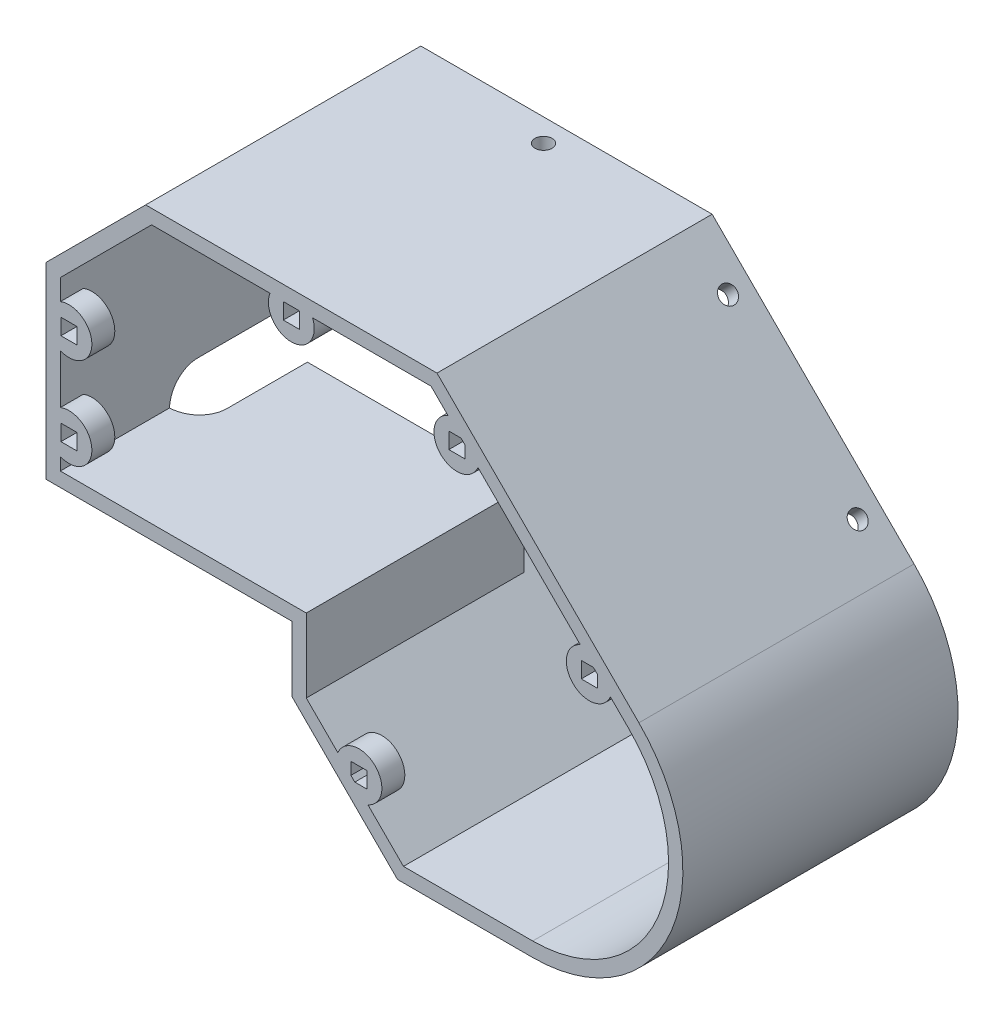
from build123d import *

# Parameters (mm, degrees)
RESSALTO_EXTRUS_O1_DEPTH = 48
ESBO_O12_R               = 1.5
CORTE_EXTRUS_O10_DEPTH   = 10
ESBO_O13_R               = 1.5
CORTE_EXTRUS_O11_DEPTH   = 10
ESBO_O14_R               = 1.5
CORTE_EXTRUS_O12_DEPTH   = 10
ESBO_O15_R               = 1.5
CORTE_EXTRUS_O13_DEPTH   = 10
CORTE_EXTRUS_O14_DEPTH   = 10
ESBO_O17_R               = 4
ESBO_O17_W               = 2.8
ESBO_O17_H               = 2.8
RESSALTO_EXTRUS_O2_DEPTH = 4
CORTE_EXTRUS_O15_DEPTH   = 10
ESBO_O20_R               = 86.409415436
CORTE_EXTRUS_O16_DEPTH   = 48


with BuildPart() as part:
    # Model → Ressalto-extrusão1 (new body)
    with BuildSketch(Plane.XY):
        with BuildLine():
            Line((-0.7, 0), (39, 0))
            Line((39, 0), (39.7, 0))
            Line((39.7, 0), (39.7, -11.380317396))
            Line((39.7, -11.380317396), (50.182424304, -21.8627417))
            Line((50.182424304, -21.8627417), (58.119682605, -29.8))
            Line((58.119682605, -29.8), (81.7, -29.8))
            ThreePointArc((81.7, -29.8), (105.905643752, -13.626305928), (100.226197667, 14.926197667))
            Line((100.226197667, 14.926197667), (65.00338056, 50.149014774))
            Line((65.00338056, 50.149014774), (50.111140335, 50.149014774))
            Line((50.111140335, 50.149014774), (14.181595121, 50.149014774))
            Line((14.181595121, 50.149014774), (-3.2, 32.767419653))
            Line((-3.2, 32.767419653), (-3.2, 5))
            Line((-3.2, 5), (-3.2, 0))
            Line((-3.2, 0), (-0.7, 0))
        make_face()
        with BuildLine():
            Line((-0.7, 2.5), (39, 2.5))
            Line((39, 2.5), (39.7, 2.5))
            Line((39.7, 2.5), (42.2, 2.5))
            Line((42.2, 2.5), (42.2, -10.34478349))
            Line((42.2, -10.34478349), (51.950191257, -20.094974747))
            Line((51.950191257, -20.094974747), (59.15521651, -27.3))
            Line((59.15521651, -27.3), (81.7, -27.3))
            ThreePointArc((81.7, -27.3), (103.595944921, -12.669597347), (98.458430714, 13.158430714))
            Line((98.458430714, 13.158430714), (63.967846654, 47.649014774))
            Line((63.967846654, 47.649014774), (50.111140335, 47.649014774))
            Line((50.111140335, 47.649014774), (15.217129027, 47.649014774))
            Line((15.217129027, 47.649014774), (-0.7, 31.731885747))
            Line((-0.7, 31.731885747), (-0.7, 2.5))
        make_face(mode=Mode.SUBTRACT)
    extrude(amount=RESSALTO_EXTRUS_O1_DEPTH)

    # Esboço12 → Corte-extrusão10 (cut)
    with BuildSketch(Plane(origin=(57.576197667, 57.576197667, 0), x_dir=(0, 0, -1), z_dir=(0.707106781, 0.707106781, 0))):
        with Locations((-44, -20.072657306)):
            Circle(ESBO_O12_R)
        with Locations((-44, -52.072657306)):
            Circle(ESBO_O12_R)
    extrude(amount=-CORTE_EXTRUS_O10_DEPTH, mode=Mode.SUBTRACT)

    # Esboço13 → Corte-extrusão11 (cut)
    with BuildSketch(Plane(origin=(0, 50.149014774, 0), x_dir=(1, 0, 0), z_dir=(0, 1, 0))):
        with Locations((39.59248784, -44)):
            Circle(ESBO_O13_R)
    extrude(amount=-CORTE_EXTRUS_O11_DEPTH, mode=Mode.SUBTRACT)

    # Esboço14 → Corte-extrusão12 (cut)
    with BuildSketch(Plane.ZY.offset(3.2)):
        with Locations((44, 23.701037279)):
            Circle(ESBO_O14_R)
        with Locations((44, 7.740898975)):
            Circle(ESBO_O14_R)
    extrude(amount=-CORTE_EXTRUS_O12_DEPTH, mode=Mode.SUBTRACT)

    # Esboço15 → Corte-extrusão13 (cut)
    with BuildSketch(Plane(origin=(14.159841302, 14.159841302, 0), x_dir=(0, 0, 1), z_dir=(-0.707106781, -0.707106781, 0))):
        with Locations((44, -46.881179593)):
            Circle(ESBO_O15_R)
    extrude(amount=-CORTE_EXTRUS_O13_DEPTH, mode=Mode.SUBTRACT)

    # Esboço16 → Corte-extrusão14 (cut)
    with BuildSketch(Plane.XY.offset(48)):
        Polygon((39.7, 0), (39.7, -7.84478349), (42.2, -10.34478349), (42.2, 2.5), (-0.7, 2.5), (-0.7, 0), align=None)
    extrude(amount=-CORTE_EXTRUS_O14_DEPTH, mode=Mode.SUBTRACT)

    # Esboço17 → Ressalto-extrusão2 (add)
    with BuildSketch(Plane(origin=(0, 0, 0), x_dir=(-1, 0, 0), z_dir=(0, 0, -1))):
        with Locations((-91.568699638, 17.926841447)):
            Circle(ESBO_O17_R)
        with Locations((-91.568699638, 17.926841447)):
            Rectangle(ESBO_O17_W, ESBO_O17_H, mode=Mode.SUBTRACT)
        with Locations((-68.47265349, 41.022887595)):
            Circle(ESBO_O17_R)
        with Locations((-68.47265349, 41.022887595)):
            Rectangle(ESBO_O17_W, ESBO_O17_H, mode=Mode.SUBTRACT)
        with Locations((-39.59248784, 46.149014774)):
            Circle(ESBO_O17_R)
        with Locations((-39.59248784, 46.149014774)):
            Rectangle(ESBO_O17_W, ESBO_O17_H, mode=Mode.SUBTRACT)
        with Locations((-0.8, 24.383709827)):
            Circle(ESBO_O17_R)
        with Locations((-0.8, 24.383709827)):
            Rectangle(ESBO_O17_W, ESBO_O17_H, mode=Mode.SUBTRACT)
        with Locations((-0.8, 8.383709827)):
            Circle(ESBO_O17_R)
        with Locations((-0.8, 8.383709827)):
            Rectangle(ESBO_O17_W, ESBO_O17_H, mode=Mode.SUBTRACT)
        with Locations((-51.388268427, -17.411731573)):
            Circle(ESBO_O17_R)
        with Locations((-51.388268427, -17.411731573)):
            Rectangle(ESBO_O17_W, ESBO_O17_H, mode=Mode.SUBTRACT)
    extrude(amount=-RESSALTO_EXTRUS_O2_DEPTH)

    # Esboço18 → Corte-extrusão15 (cut)
    with BuildSketch(Plane.XY.offset(48)):
        Polygon((-0.7, 31.731885747), (-32.431885747, 0), (-0.7, 0), align=None)
    extrude(amount=-CORTE_EXTRUS_O15_DEPTH, mode=Mode.SUBTRACT)

    # Esboço19 → Corte-Revolução1 (revolve, cut)
    with BuildSketch(Plane.ZY.offset(3.2)):
        with BuildLine():
            Line((19, 0), (29, 0))
            Line((29, 0), (38.25689259, 0))
            Line((38.25689259, 0), (38.25689259, 8))
            Line((38.25689259, 8), (24, 8))
            ThreePointArc((24, 8), (20.464466094, 6.535533906), (19, 3))
            Line((19, 3), (19, 0))
        make_face()
    revolve(axis=Axis((-3.2, 0, 19), (0, 0, 1)), mode=Mode.SUBTRACT)


with BuildPart() as body_2:
    # Espelhar1: mirrored copy
    add(part.part.mirror(Plane(origin=(81.7, -3.6, 48), x_dir=(1, 0, 0), z_dir=(0, 0, 1))))


with BuildPart() as part_1:
    add(part.part)

    # Esboço20 → Corte-extrusão16 (cut)
    with BuildSketch(Plane(origin=(0, 0, 0), x_dir=(-1, 0, 0), z_dir=(0, 0, -1))):
        with Locations((-60.26581621, 14.045976116)):
            Circle(ESBO_O20_R)
    extrude(amount=-CORTE_EXTRUS_O16_DEPTH, mode=Mode.SUBTRACT)


solid = body_2.part
